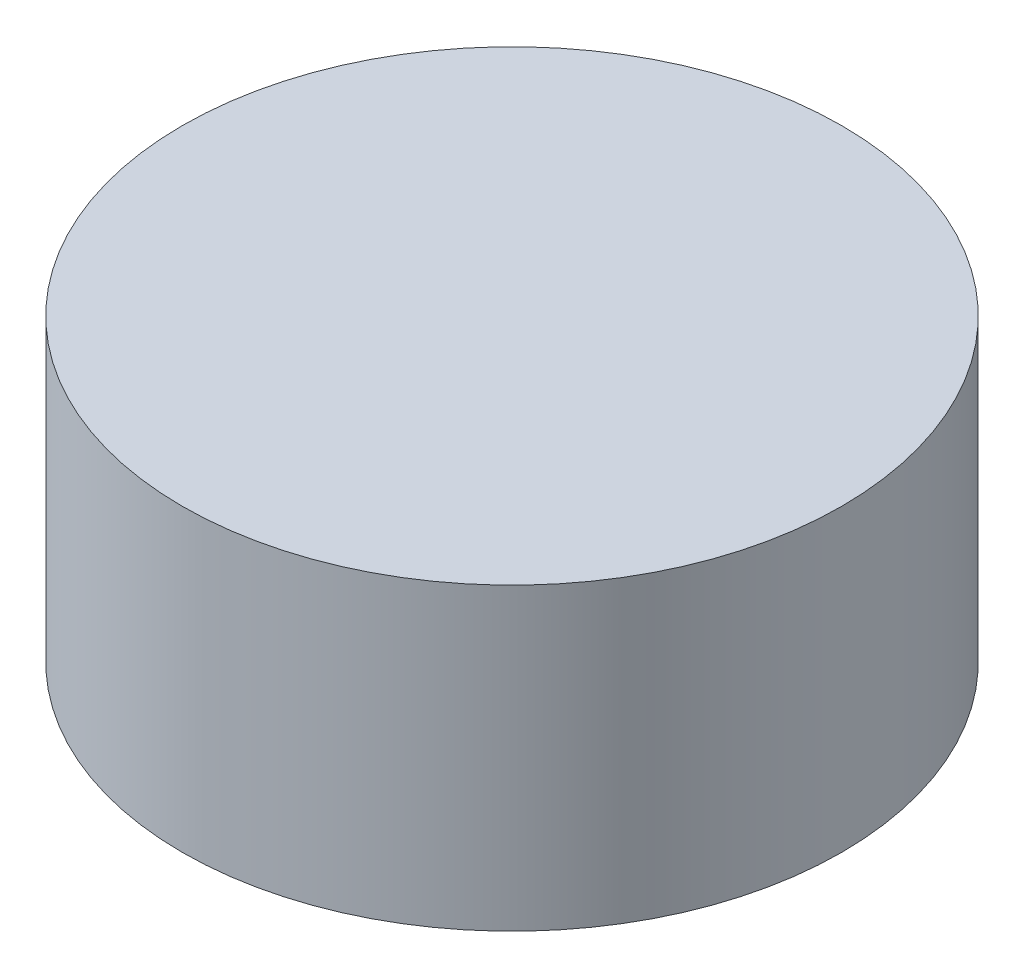
from build123d import *

# Parameters (mm, degrees)
SKETCH_2_R      = 5.5
EXTRUDE_1_DEPTH = 5


with BuildPart() as part:
    # 草圖2 → 填料-伸長1 (new body)
    with BuildSketch(Plane(origin=(0, 0, 0), x_dir=(1, 0, 0), z_dir=(0, 1, 0))):
        Circle(SKETCH_2_R)
    extrude(amount=EXTRUDE_1_DEPTH)


solid = part.part
